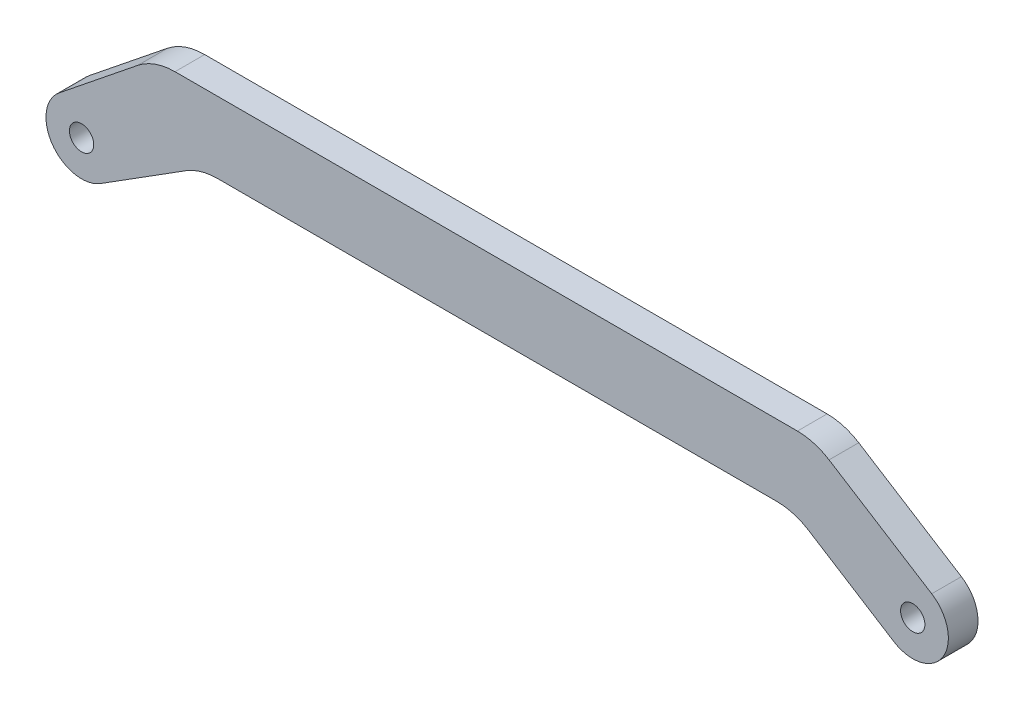
from build123d import *

# Parameters (mm, degrees)
SCHIZZO1_R                   = 2.05
ESTRUSIONE_ESTRUSIONE1_DEPTH = 5


with BuildPart() as part:
    # Schizzo1 → Estrusione-Estrusione1 (new body)
    with BuildSketch(Plane.XY):
        with BuildLine():
            Line((-3.757019077, 4.678120099), (9.474796834, 15.30465036))
            ThreePointArc((9.474796834, 15.30465036), (12.41750963, 16.940934337), (15.736495295, 17.507783529))
            Line((15.736495295, 17.507783529), (120.577440721, 17.507783529))
            ThreePointArc((120.577440721, 17.507783529), (123.351342788, 17.115356965), (125.907534283, 15.968876995))
            Line((125.907534283, 15.968876995), (143.198056137, 5.076656079))
            ThreePointArc((143.198056137, 5.076656079), (145.076656079, -3.198056137), (136.801943863, -5.076656079))
            Line((136.801943863, -5.076656079), (122.442889956, 3.968876995))
            ThreePointArc((122.442889956, 3.968876995), (119.886698461, 5.115356965), (117.112796394, 5.507783529))
            Line((117.112796394, 5.507783529), (22.887203606, 5.507783529))
            ThreePointArc((22.887203606, 5.507783529), (20.113301539, 5.115356965), (17.557110044, 3.968876995))
            Line((17.557110044, 3.968876995), (3.198056137, -5.076656079))
            ThreePointArc((3.198056137, -5.076656079), (-4.885388875, -3.483242102), (-3.757019077, 4.678120099))
        make_face()
        Circle(SCHIZZO1_R, mode=Mode.SUBTRACT)
        with Locations((140, 0)):
            Circle(SCHIZZO1_R, mode=Mode.SUBTRACT)
    extrude(amount=ESTRUSIONE_ESTRUSIONE1_DEPTH)


solid = part.part
